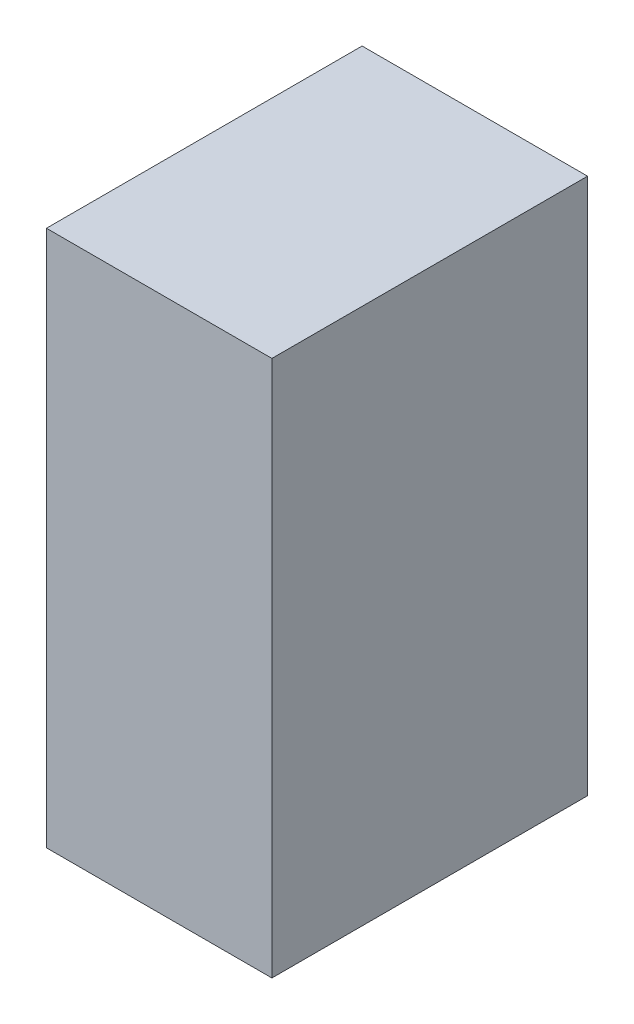
from build123d import *

# Parameters (mm, degrees)
SKETCH1_W           = 25
SKETCH1_H           = 59.497625249
BOSS_EXTRUDE1_DEPTH = 35


with BuildPart() as part:
    # Sketch1 → Boss-Extrude1 (new body)
    with BuildSketch(Plane.XY):
        with Locations((-0.042882398, 595.251187375)):
            Rectangle(SKETCH1_W, SKETCH1_H)
    extrude(amount=BOSS_EXTRUDE1_DEPTH)


solid = part.part
